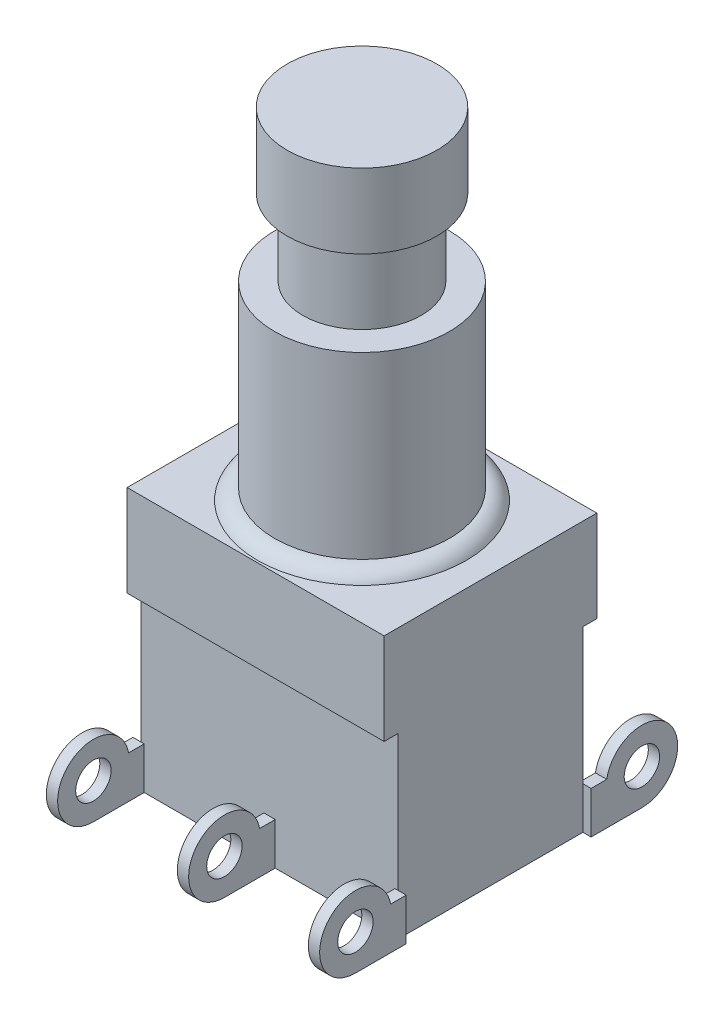
from build123d import *

# Parameters (mm, degrees)
SKETCH2_W               = 17.3355
SKETCH2_H               = 14.351
BOSS_EXTRUDE1_DEPTH     = 6.1722
SKETCH3_W               = 17.3355
SKETCH3_H               = 12.4714
BOSS_EXTRUDE2_DEPTH     = 12.0142
SKETCH4_R               = 1.1938
BOSS_EXTRUDE3_DEPTH     = 0.381
LPATTERN1_COUNT         = 2
LPATTERN1_PITCH         = 8.8392
LPATTERN1_COL_COUNT     = 2
LPATTERN1_COL_PITCH     = 8.8392
MIRROR1_COPY_1_SKETCH_R = 1.1938
MIRROR1_COPY_1_DEPTH    = 0.381
MIRROR1_COPY_2_SKETCH_R = 1.1938
MIRROR1_COPY_2_DEPTH    = 0.381


with BuildPart() as part:
    # Sketch1 → Revolve1 (revolve)
    with BuildSketch(Plane.XY):
        with BuildLine():
            Line((0, 0), (7.0358, 0))
            ThreePointArc((7.0358, 0), (6.5659, 0.518885714), (5.8928, 0.7112))
            Line((5.8928, 0.7112), (5.8928, 12.8016))
            Line((5.8928, 12.8016), (4.0005, 12.8016))
            Line((4.0005, 12.8016), (4.0005, 17.9578))
            Line((4.0005, 17.9578), (5.04825, 17.9578))
            Line((5.04825, 17.9578), (5.04825, 22.9743))
            Line((5.04825, 22.9743), (0, 22.9743))
            Line((0, 22.9743), (0, 0))
        make_face()
    revolve(axis=Axis((0, 17.332868294, 0), (0, -1, 0)))

    # Sketch2 → Boss-Extrude1 (add)
    with BuildSketch(Plane.XZ):
        Rectangle(SKETCH2_W, SKETCH2_H)
    extrude(amount=BOSS_EXTRUDE1_DEPTH)

    # Sketch3 → Boss-Extrude2 (add)
    with BuildSketch(Plane.XZ.offset(6.1722)):
        Rectangle(SKETCH3_W, SKETCH3_H)
    extrude(amount=BOSS_EXTRUDE2_DEPTH)

    # Sketch4 → Boss-Extrude3 (add, symmetric)
    with BuildSketch(Plane(origin=(0, 0, 0), x_dir=(0, 0, -1), z_dir=(1, 0, 0))):
        with BuildLine():
            Line((6.2357, -18.1864), (9.6647, -18.1864))
            ThreePointArc((9.6647, -18.1864), (11.517333585, -14.227334736), (7.290649082, -15.3416))
            Line((7.290649082, -15.3416), (6.2357, -15.3416))
            Line((6.2357, -15.3416), (6.2357, -18.1864))
        make_face()
        with Locations((9.6647, -15.7734)):
            Circle(SKETCH4_R, mode=Mode.SUBTRACT)
    boss_extrude3 = extrude(amount=BOSS_EXTRUDE3_DEPTH, both=True)

    # LPattern1: Boss-Extrude3 ×2
    with Locations(*[(i * LPATTERN1_PITCH, 0, 0) for i in range(1, LPATTERN1_COUNT)]):
        add(boss_extrude3)

    # LPattern1 col: Boss-Extrude3 ×2
    with Locations(*[(-i * LPATTERN1_COL_PITCH, 0, 0) for i in range(1, LPATTERN1_COL_COUNT)]):
        add(boss_extrude3)

    # Mirror1: Boss-Extrude3 across plane
    add(boss_extrude3.mirror(Plane.XY))

    # Mirror1 copy 1 sketch → Mirror1 copy 1 (add, symmetric)
    with BuildSketch(Plane(origin=(8.8392, 0, 0), x_dir=(0, 0, 1), z_dir=(1, 0, 0))):
        with BuildLine():
            Line((6.2357, 18.1864), (9.6647, 18.1864))
            ThreePointArc((9.6647, 18.1864), (11.517333585, 14.227334736), (7.290649082, 15.3416))
            Line((7.290649082, 15.3416), (6.2357, 15.3416))
            Line((6.2357, 15.3416), (6.2357, 18.1864))
        make_face()
        with Locations((9.6647, 15.7734)):
            Circle(MIRROR1_COPY_1_SKETCH_R, mode=Mode.SUBTRACT)
    extrude(amount=MIRROR1_COPY_1_DEPTH, both=True)

    # Mirror1 copy 2 sketch → Mirror1 copy 2 (add, symmetric)
    with BuildSketch(Plane(origin=(-8.8392, 0, 0), x_dir=(0, 0, 1), z_dir=(1, 0, 0))):
        with BuildLine():
            Line((6.2357, 18.1864), (9.6647, 18.1864))
            ThreePointArc((9.6647, 18.1864), (11.517333585, 14.227334736), (7.290649082, 15.3416))
            Line((7.290649082, 15.3416), (6.2357, 15.3416))
            Line((6.2357, 15.3416), (6.2357, 18.1864))
        make_face()
        with Locations((9.6647, 15.7734)):
            Circle(MIRROR1_COPY_2_SKETCH_R, mode=Mode.SUBTRACT)
    extrude(amount=MIRROR1_COPY_2_DEPTH, both=True)


solid = part.part
